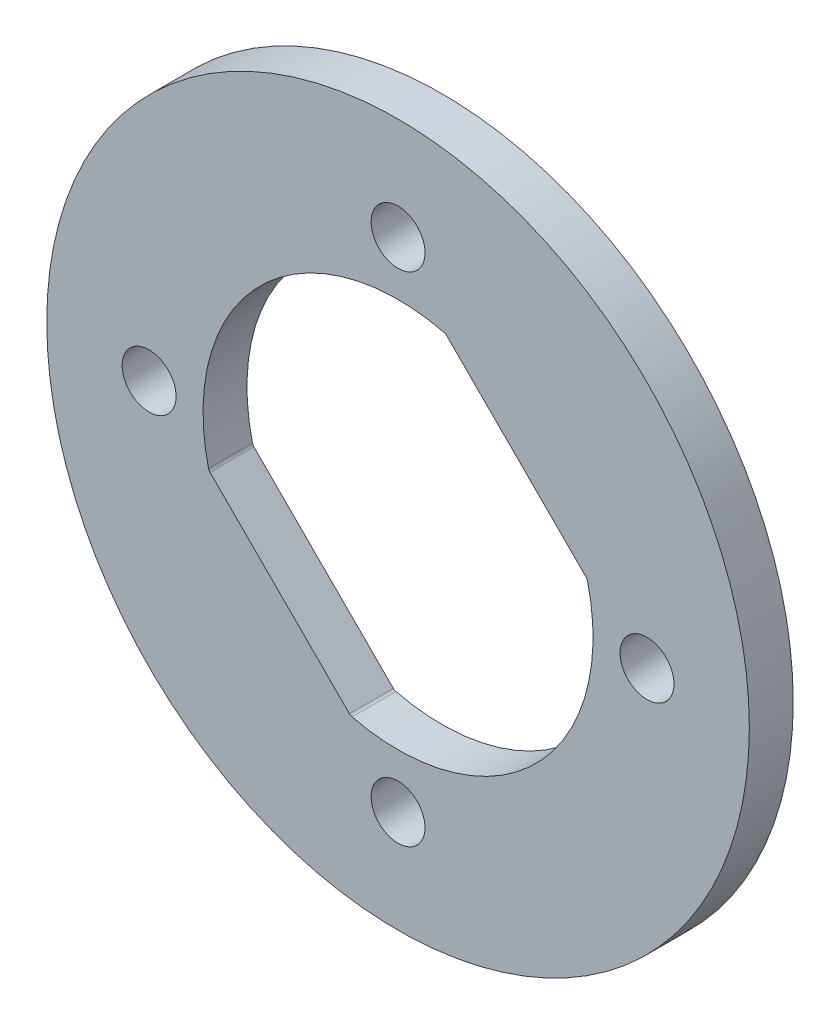
from build123d import *

# Parameters (mm, degrees)
SKETCH3_R           = 12.7
SKETCH3_R_2         = 0.975
BOSS_EXTRUDE2_DEPTH = 1.5875


with BuildPart() as part:
    # Sketch3 → Boss-Extrude2 (new body)
    with BuildSketch(Plane.XY):
        Circle(SKETCH3_R)
        with BuildLine():
            ThreePointArc((6.269554118, 8.885849209), (0, 10.875), (-6.269554118, 8.885849209))
            Line((-6.269554118, 8.885849209), (-5.055813485, 7.672108576))
            ThreePointArc((-5.055813485, 7.672108576), (-5.055813485, 5.055813485), (-7.672108576, 5.055813485))
            Line((-7.672108576, 5.055813485), (-8.885849209, 6.269554118))
            ThreePointArc((-8.885849209, 6.269554118), (-10.875, 0), (-8.885849209, -6.269554118))
            Line((-8.885849209, -6.269554118), (-7.672108576, -5.055813485))
            ThreePointArc((-7.672108576, -5.055813485), (-5.055813485, -5.055813485), (-5.055813485, -7.672108576))
            Line((-5.055813485, -7.672108576), (-6.269554118, -8.885849209))
            ThreePointArc((-6.269554118, -8.885849209), (0, -10.875), (6.269554118, -8.885849209))
            Line((6.269554118, -8.885849209), (5.055813485, -7.672108576))
            ThreePointArc((5.055813485, -7.672108576), (5.055813485, -5.055813485), (7.672108576, -5.055813485))
            Line((7.672108576, -5.055813485), (8.885849209, -6.269554118))
            ThreePointArc((8.885849209, -6.269554118), (10.875, 0), (8.885849209, 6.269554118))
            Line((8.885849209, 6.269554118), (7.672108576, 5.055813485))
            ThreePointArc((7.672108576, 5.055813485), (5.055813485, 5.055813485), (5.055813485, 7.672108576))
            Line((5.055813485, 7.672108576), (6.269554118, 8.885849209))
        make_face(mode=Mode.SUBTRACT)
        with BuildLine():
            Line((5.055813485, 7.672108576), (6.269554118, 8.885849209))
            ThreePointArc((6.269554118, 8.885849209), (0, 10.875), (-6.269554118, 8.885849209))
            Line((-6.269554118, 8.885849209), (-5.055813485, 7.672108576))
            ThreePointArc((-5.055813485, 7.672108576), (-5.055813485, 5.055813485), (-7.672108576, 5.055813485))
            Line((-7.672108576, 5.055813485), (-8.885849209, 6.269554118))
            ThreePointArc((-8.885849209, 6.269554118), (-10.875, 0), (-8.885849209, -6.269554118))
            Line((-8.885849209, -6.269554118), (-7.672108576, -5.055813485))
            ThreePointArc((-7.672108576, -5.055813485), (-5.055813485, -5.055813485), (-5.055813485, -7.672108576))
            Line((-5.055813485, -7.672108576), (-6.269554118, -8.885849209))
            ThreePointArc((-6.269554118, -8.885849209), (0, -10.875), (6.269554118, -8.885849209))
            Line((6.269554118, -8.885849209), (5.055813485, -7.672108576))
            ThreePointArc((5.055813485, -7.672108576), (5.055813485, -5.055813485), (7.672108576, -5.055813485))
            Line((7.672108576, -5.055813485), (8.885849209, -6.269554118))
            ThreePointArc((8.885849209, -6.269554118), (10.875, 0), (8.885849209, 6.269554118))
            Line((8.885849209, 6.269554118), (7.672108576, 5.055813485))
            ThreePointArc((7.672108576, 5.055813485), (5.055813485, 5.055813485), (5.055813485, 7.672108576))
        make_face()
        with Locations((0, 9.000000134)):
            Circle(SKETCH3_R_2, mode=Mode.SUBTRACT)
        with Locations((9.000000134, 0)):
            Circle(SKETCH3_R_2, mode=Mode.SUBTRACT)
        with Locations((0, -9.000000134)):
            Circle(SKETCH3_R_2, mode=Mode.SUBTRACT)
        with Locations((-9.000000134, 0)):
            Circle(SKETCH3_R_2, mode=Mode.SUBTRACT)
        with BuildLine():
            ThreePointArc((6.850845531, 1.663855614), (6.830865544, 1.714608205), (6.79791666, 1.758075393))
            Line((6.79791666, 1.758075393), (1.758075393, 6.79791666))
            ThreePointArc((1.758075393, 6.79791666), (1.714608205, 6.830865544), (1.663855614, 6.850845531))
            ThreePointArc((1.663855614, 6.850845531), (-4.985102807, 4.985102807), (-6.850845531, -1.663855614))
            ThreePointArc((-6.850845531, -1.663855614), (-6.830865544, -1.714608205), (-6.79791666, -1.758075393))
            Line((-6.79791666, -1.758075393), (-1.758075393, -6.79791666))
            ThreePointArc((-1.758075393, -6.79791666), (-1.714608205, -6.830865544), (-1.663855614, -6.850845531))
            ThreePointArc((-1.663855614, -6.850845531), (4.985102807, -4.985102807), (6.850845531, 1.663855614))
        make_face(mode=Mode.SUBTRACT)
    extrude(amount=BOSS_EXTRUDE2_DEPTH)


solid = part.part
